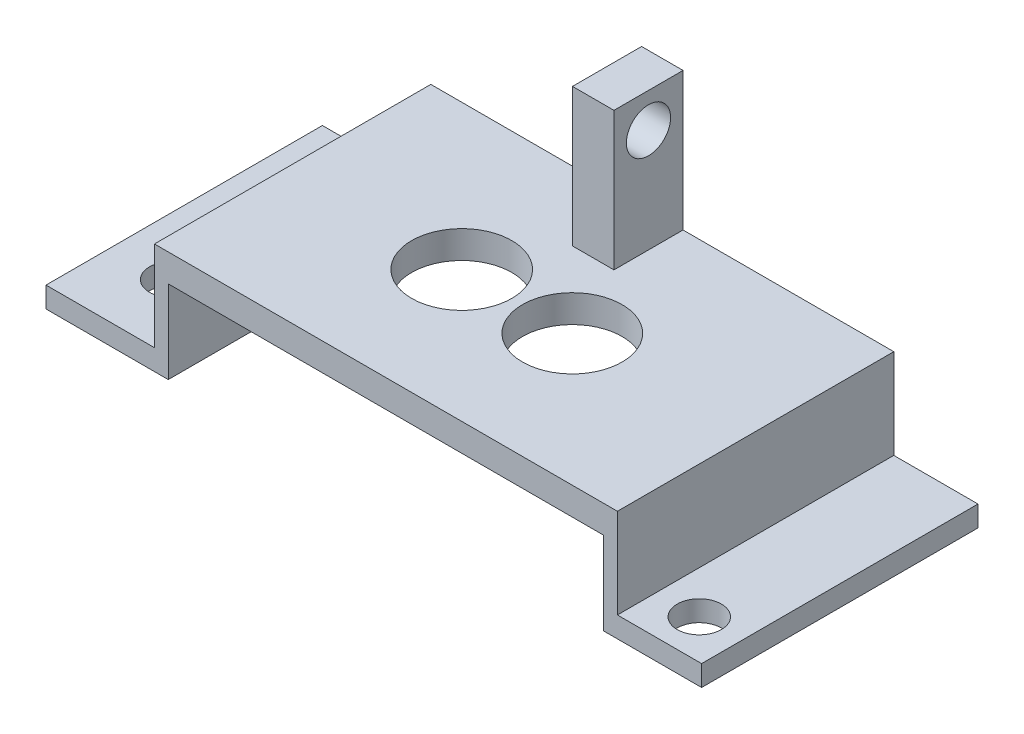
from build123d import *

# Parameters (mm, degrees)
SKETCH_1_W          = 33.5
SKETCH_1_H          = 15
SKETCH_1_R          = 3.624978968
SKETCH_1_R_2        = 3.60228421
EXTRUDE_1_DEPTH     = 2
SKETCH_1_3_W        = 1
SKETCH_1_3_H        = 15
EXTRUDE_2_DEPTH     = 6
SKETCH_2_R          = 1.6
EXTRUDE_3_DEPTH     = 1.5
EXTRUDE_4_DEPTH     = 5
SKETCH_4_W          = 3
SKETCH_4_H          = 5
EXTRUDE_5_DEPTH     = 10
SKETCH_5_R          = 1.6
CUT_EXTRUDE_1_DEPTH = 10


with BuildPart() as part:
    # 草图1 → 凸台-拉伸1 (new body)
    with BuildSketch(Plane(origin=(0, 0, 0), x_dir=(1, 0, 0), z_dir=(0, 1, 0))):
        Rectangle(SKETCH_1_W, SKETCH_1_H)
        with Locations((-4.032505812, 2.018294601)):
            Circle(SKETCH_1_R, mode=Mode.SUBTRACT)
        with Locations((3.968074022, 2.018294601)):
            Circle(SKETCH_1_R_2, mode=Mode.SUBTRACT)
    extrude(amount=EXTRUDE_1_DEPTH)

    # 草图1<3> → 凸台-拉伸2 (add)
    with BuildSketch(Plane(origin=(0, 0, 0), x_dir=(1, 0, 0), z_dir=(0, 1, 0))):
        with Locations((16.25, 0)):
            Rectangle(SKETCH_1_3_W, SKETCH_1_3_H)
        with Locations((-16.25, 0)):
            Rectangle(SKETCH_1_3_W, SKETCH_1_3_H)
    extrude(amount=-EXTRUDE_2_DEPTH)

    # 草图2 → 凸台-拉伸3 (add)
    # profile 1 of 2: a face of its own
    with BuildSketch(Plane.XZ.offset(6)):
        Polygon((-16.75, -7.5), (-24.597168746, -7.5), (-24.597168746, 0), (-24.597168746, 7.5), (-16.75, 7.5), (-16.75, 0), align=None)
        with Locations((-20.395135673, 2.61052916)):
            Circle(SKETCH_2_R, mode=Mode.SUBTRACT)
    # profile 2 of 2: a face of its own
    with BuildSketch(Plane.XZ.offset(6)):
        Polygon((16.75, 7.5), (22.842739313, 7.5), (22.842739313, 0), (22.842739313, -7.5), (16.75, -7.5), (16.75, 0), align=None)
        with Locations((19.826698125, 4.651883457)):
            Circle(SKETCH_2_R, mode=Mode.SUBTRACT)
    extrude(amount=-EXTRUDE_3_DEPTH)

    # 草图3 → 凸台-拉伸4 (add)
    with BuildSketch(Plane(origin=(0, 0, -7.5), x_dir=(-1, 0, 0), z_dir=(0, 0, -1))):
        Polygon((-16.75, 2), (-16.75, -4.5), (-22.842739313, -4.5), (-22.842739313, -6), (-15.75, -6), (-15.75, 0), (15.75, 0), (15.75, -6), (24.597168746, -6), (24.597168746, -4.5), (16.75, -4.5), (16.75, 2), align=None)
    extrude(amount=EXTRUDE_4_DEPTH)

    # 草图4 → 凸台-拉伸5 (add)
    with BuildSketch(Plane(origin=(0, 2, 0), x_dir=(1, 0, 0), z_dir=(0, 1, 0))):
        with Locations((0, 10)):
            Rectangle(SKETCH_4_W, SKETCH_4_H)
    extrude(amount=EXTRUDE_5_DEPTH)

    # 草图5 → 切除-拉伸1 (cut)
    with BuildSketch(Plane(origin=(1.5, 0, 0), x_dir=(0, 0, -1), z_dir=(1, 0, 0))):
        with Locations((10, 9.5)):
            Circle(SKETCH_5_R)
    extrude(amount=-CUT_EXTRUDE_1_DEPTH, mode=Mode.SUBTRACT)


solid = part.part
